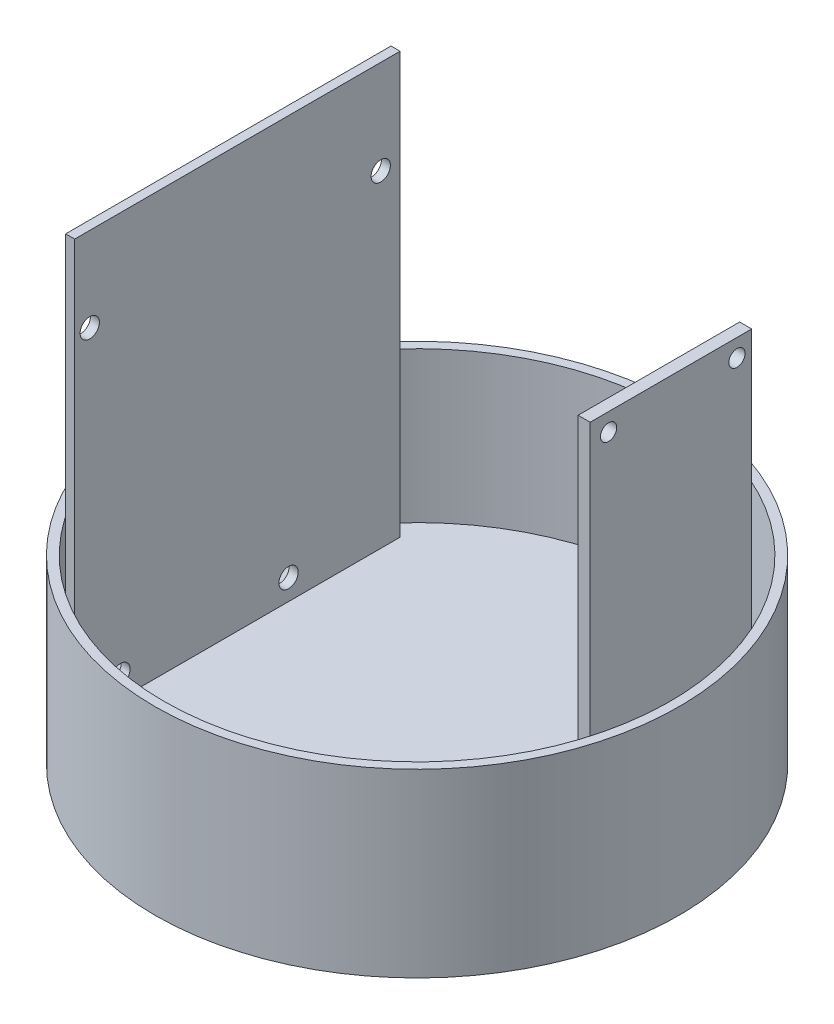
from build123d import *

# Parameters (mm, degrees)
SKETCH1_R               = 43.5
BOSS_EXTRUDE1_DEPTH     = 30
SKETCH2_R               = 42
CUT_EXTRUDE1_DEPTH      = 1
CUT_EXTRUDE1_DEPTH_BACK = 25
SKETCH6_W               = 1.5
SKETCH6_H               = 54
BOSS_EXTRUDE4_DEPTH     = 80
SKETCH7_W               = 54
SKETCH7_H               = 6.26870776
CUT_EXTRUDE2_DEPTH      = 15.49497474
SKETCH8_W               = 54
SKETCH8_H               = 3.87063504
CUT_EXTRUDE3_DEPTH      = 15.49497474
CUT_EXTRUDE5_REACH      = 16.495
SKETCH9_R               = 1.6
SKETCH10_W              = 2
SKETCH10_H              = 28.990761916
BOSS_EXTRUDE5_DEPTH     = 67
CUT_EXTRUDE6_REACH      = 16.562
SKETCH11_W              = 28.990761916
SKETCH11_H              = 6.298062211
CUT_EXTRUDE7_REACH      = 16.562
SKETCH12_W              = 2.183875445
SKETCH12_H              = 60.701937789
CUT_EXTRUDE8_REACH      = 16.562
SKETCH13_R              = 1.35


with BuildPart() as part:
    # Sketch1 → Boss-Extrude1 (new body)
    with BuildSketch(Plane(origin=(0, 0, 0), x_dir=(1, 0, 0), z_dir=(0, 1, 0))):
        Circle(SKETCH1_R)
    extrude(amount=BOSS_EXTRUDE1_DEPTH)

    # Sketch2 → Cut-Extrude1 (cut, two sides)
    with BuildSketch(Plane(origin=(0, 30, 0), x_dir=(1, 0, 0), z_dir=(0, 1, 0))) as cut_extrude1_sk:
        Circle(SKETCH2_R)
    extrude(amount=CUT_EXTRUDE1_DEPTH, mode=Mode.SUBTRACT)
    extrude(cut_extrude1_sk.sketch, amount=-CUT_EXTRUDE1_DEPTH_BACK, mode=Mode.SUBTRACT)

    # Sketch6 → Boss-Extrude4 (add)
    with BuildSketch(Plane(origin=(0, 5, 0), x_dir=(1, 0, 0), z_dir=(0, 1, 0))):
        with Locations((-29.75502526, -0.820126033)):
            Rectangle(SKETCH6_W, SKETCH6_H)
    extrude(amount=BOSS_EXTRUDE4_DEPTH)

    # Sketch7 → Cut-Extrude2 (cut, through all)
    with BuildSketch(Plane(origin=(-29.00502526, 0, 0), x_dir=(0, 0, -1), z_dir=(1, 0, 0))):
        with Locations((-0.820126033, 81.86564612)):
            Rectangle(SKETCH7_W, SKETCH7_H)
    extrude(amount=-CUT_EXTRUDE2_DEPTH, mode=Mode.SUBTRACT)

    # Sketch8 → Cut-Extrude3 (cut, through all)
    with BuildSketch(Plane(origin=(-29.00502526, 0, 0), x_dir=(0, 0, -1), z_dir=(1, 0, 0))):
        with Locations((-0.820126033, 76.79597472)):
            Rectangle(SKETCH8_W, SKETCH8_H)
    extrude(amount=-CUT_EXTRUDE3_DEPTH, mode=Mode.SUBTRACT)

    # Sketch9 → Cut-Extrude5 (cut, up to next)
    with BuildSketch(Plane(origin=(-29.00502526, 0, 0), x_dir=(0, 0, -1), z_dir=(1, 0, 0)), mode=Mode.PRIVATE) as cut_extrude5_sk1:
        with Locations((-25.320126033, 60.8606572)):
            Circle(SKETCH9_R)
    cut_extrude5_tool1 = extrude(cut_extrude5_sk1.sketch, amount=-CUT_EXTRUDE5_REACH, mode=Mode.PRIVATE) & part.part
    add(cut_extrude5_tool1.solids().sort_by_distance((-29.005025, 60.860657, 25.320126))[0], mode=Mode.SUBTRACT)
    # Sketch9 → Cut-Extrude5 (cut, up to next)
    with BuildSketch(Plane(origin=(-29.00502526, 0, 0), x_dir=(0, 0, -1), z_dir=(1, 0, 0)), mode=Mode.PRIVATE) as cut_extrude5_sk2:
        with Locations((22.979873967, 59.2606572)):
            Circle(SKETCH9_R)
    cut_extrude5_tool2 = extrude(cut_extrude5_sk2.sketch, amount=-CUT_EXTRUDE5_REACH, mode=Mode.PRIVATE) & part.part
    add(cut_extrude5_tool2.solids().sort_by_distance((-29.005025, 59.260657, -22.979874))[0], mode=Mode.SUBTRACT)
    # Sketch9 → Cut-Extrude5 (cut, up to next)
    with BuildSketch(Plane(origin=(-29.00502526, 0, 0), x_dir=(0, 0, -1), z_dir=(1, 0, 0)), mode=Mode.PRIVATE) as cut_extrude5_sk3:
        with Locations((7.679873967, 8.4606572)):
            Circle(SKETCH9_R)
    cut_extrude5_tool3 = extrude(cut_extrude5_sk3.sketch, amount=-CUT_EXTRUDE5_REACH, mode=Mode.PRIVATE) & part.part
    add(cut_extrude5_tool3.solids().sort_by_distance((-29.005025, 8.460657, -7.679874))[0], mode=Mode.SUBTRACT)
    # Sketch9 → Cut-Extrude5 (cut, up to next)
    with BuildSketch(Plane(origin=(-29.00502526, 0, 0), x_dir=(0, 0, -1), z_dir=(1, 0, 0)), mode=Mode.PRIVATE) as cut_extrude5_sk4:
        with Locations((-20.220126033, 8.4606572)):
            Circle(SKETCH9_R)
    cut_extrude5_tool4 = extrude(cut_extrude5_sk4.sketch, amount=-CUT_EXTRUDE5_REACH, mode=Mode.PRIVATE) & part.part
    add(cut_extrude5_tool4.solids().sort_by_distance((-29.005025, 8.460657, 20.220126))[0], mode=Mode.SUBTRACT)

    # Sketch10 → Boss-Extrude5 (add)
    with BuildSketch(Plane(origin=(0, 5, 0), x_dir=(1, 0, 0), z_dir=(0, 1, 0))):
        with Locations((29.938305356, 10.104953072)):
            Rectangle(SKETCH10_W, SKETCH10_H)
    extrude(amount=BOSS_EXTRUDE5_DEPTH)

    # Sketch11 → Cut-Extrude6 (cut, up to next)
    with BuildSketch(Plane.ZY.offset(-28.938305356), mode=Mode.PRIVATE) as cut_extrude6_sk1:
        with Locations((-10.104953072, 68.850968894)):
            Rectangle(SKETCH11_W, SKETCH11_H)
    cut_extrude6_tool1 = extrude(cut_extrude6_sk1.sketch, amount=-CUT_EXTRUDE6_REACH, mode=Mode.PRIVATE) & part.part
    add(cut_extrude6_tool1.solids().sort_by_distance((28.938305, 68.850969, -10.104953))[0], mode=Mode.SUBTRACT)

    # Sketch12 → Cut-Extrude7 (cut, up to next)
    with BuildSketch(Plane.ZY.offset(-28.938305356), mode=Mode.PRIVATE) as cut_extrude7_sk1:
        with Locations((3.298490164, 35.350968894)):
            Rectangle(SKETCH12_W, SKETCH12_H)
    cut_extrude7_tool1 = extrude(cut_extrude7_sk1.sketch, amount=-CUT_EXTRUDE7_REACH, mode=Mode.PRIVATE) & part.part
    add(cut_extrude7_tool1.solids().sort_by_distance((28.938305, 35.350969, 3.29849))[0], mode=Mode.SUBTRACT)

    # Sketch13 → Cut-Extrude8 (cut, up to next)
    with BuildSketch(Plane.ZY.offset(-28.938305356), mode=Mode.PRIVATE) as cut_extrude8_sk1:
        with Locations((-22.15033403, 62.75)):
            Circle(SKETCH13_R)
    cut_extrude8_tool1 = extrude(cut_extrude8_sk1.sketch, amount=-CUT_EXTRUDE8_REACH, mode=Mode.PRIVATE) & part.part
    add(cut_extrude8_tool1.solids().sort_by_distance((28.938305, 62.75, -22.150334))[0], mode=Mode.SUBTRACT)
    # Sketch13 → Cut-Extrude8 (cut, up to next)
    with BuildSketch(Plane.ZY.offset(-28.938305356), mode=Mode.PRIVATE) as cut_extrude8_sk2:
        with Locations((-0.85033403, 62.75)):
            Circle(SKETCH13_R)
    cut_extrude8_tool2 = extrude(cut_extrude8_sk2.sketch, amount=-CUT_EXTRUDE8_REACH, mode=Mode.PRIVATE) & part.part
    add(cut_extrude8_tool2.solids().sort_by_distance((28.938305, 62.75, -0.850334))[0], mode=Mode.SUBTRACT)
    # Sketch13 → Cut-Extrude8 (cut, up to next)
    with BuildSketch(Plane.ZY.offset(-28.938305356), mode=Mode.PRIVATE) as cut_extrude8_sk3:
        with Locations((-22.15033403, 7.45)):
            Circle(SKETCH13_R)
    cut_extrude8_tool3 = extrude(cut_extrude8_sk3.sketch, amount=-CUT_EXTRUDE8_REACH, mode=Mode.PRIVATE) & part.part
    add(cut_extrude8_tool3.solids().sort_by_distance((28.938305, 7.45, -22.150334))[0], mode=Mode.SUBTRACT)
    # Sketch13 → Cut-Extrude8 (cut, up to next)
    with BuildSketch(Plane.ZY.offset(-28.938305356), mode=Mode.PRIVATE) as cut_extrude8_sk4:
        with Locations((-0.85033403, 7.45)):
            Circle(SKETCH13_R)
    cut_extrude8_tool4 = extrude(cut_extrude8_sk4.sketch, amount=-CUT_EXTRUDE8_REACH, mode=Mode.PRIVATE) & part.part
    add(cut_extrude8_tool4.solids().sort_by_distance((28.938305, 7.45, -0.850334))[0], mode=Mode.SUBTRACT)


solid = part.part
